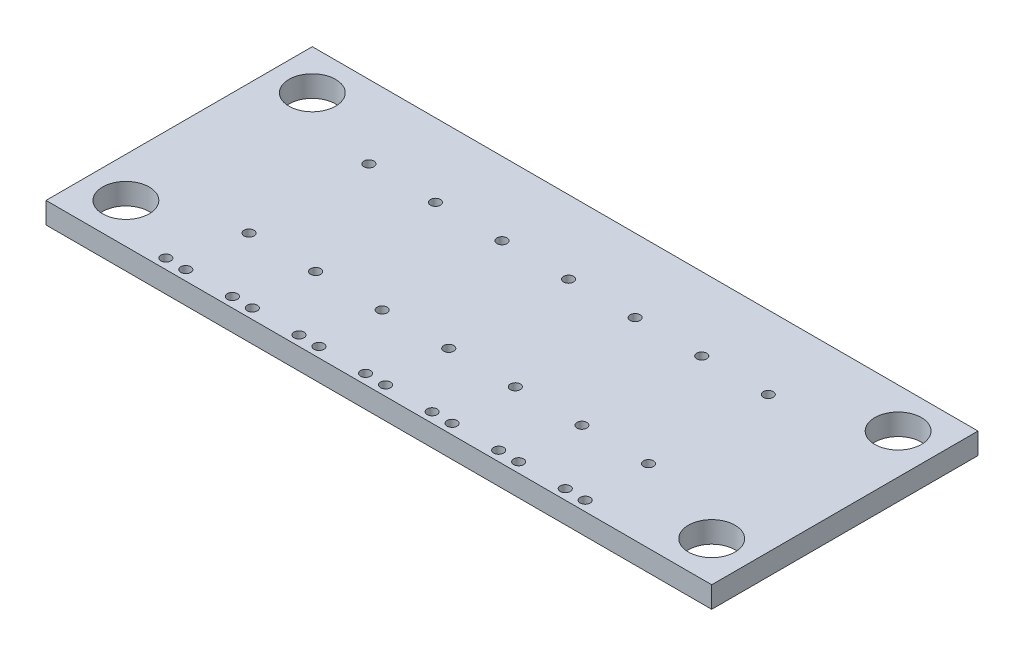
from build123d import *

# Parameters (mm, degrees)
SKETCH1_W           = 50
SKETCH1_H           = 20
SKETCH1_R           = 1.75
BOSS_EXTRUDE1_DEPTH = 1.6
SKETCH3_R           = 0.375
CUT_EXTRUDE1_DEPTH  = 2.6


with BuildPart() as part:
    # Sketch1 → Boss-Extrude1 (new body)
    with BuildSketch(Plane(origin=(0, 0, 0), x_dir=(1, 0, 0), z_dir=(0, 1, 0))):
        with Locations((25, 10)):
            Rectangle(SKETCH1_W, SKETCH1_H)
        with Locations((3, 17)):
            Circle(SKETCH1_R, mode=Mode.SUBTRACT)
        with Locations((47, 3)):
            Circle(SKETCH1_R, mode=Mode.SUBTRACT)
        with Locations((3, 3)):
            Circle(SKETCH1_R, mode=Mode.SUBTRACT)
        with Locations((47, 17)):
            Circle(SKETCH1_R, mode=Mode.SUBTRACT)
    extrude(amount=BOSS_EXTRUDE1_DEPTH)

    # Sketch3 → Cut-Extrude1 (cut, through all)
    with BuildSketch(Plane(origin=(0, 1.6, 0), x_dir=(1, 0, 0), z_dir=(0, 1, 0))):
        with Locations((8.25, 0.75)):
            Circle(SKETCH3_R)
        with Locations((9.75, 0.75)):
            Circle(SKETCH3_R)
        with Locations((9.75, 5.5)):
            Circle(SKETCH3_R)
        with Locations((9.75, 14.5)):
            Circle(SKETCH3_R)
        with Locations((13.25, 0.75)):
            Circle(SKETCH3_R)
        with Locations((14.75, 0.75)):
            Circle(SKETCH3_R)
        with Locations((14.75, 14.5)):
            Circle(SKETCH3_R)
        with Locations((14.75, 5.5)):
            Circle(SKETCH3_R)
        with Locations((18.25, 0.75)):
            Circle(SKETCH3_R)
        with Locations((19.75, 0.75)):
            Circle(SKETCH3_R)
        with Locations((19.75, 14.5)):
            Circle(SKETCH3_R)
        with Locations((19.75, 5.5)):
            Circle(SKETCH3_R)
        with Locations((23.25, 0.75)):
            Circle(SKETCH3_R)
        with Locations((24.75, 0.75)):
            Circle(SKETCH3_R)
        with Locations((24.75, 14.5)):
            Circle(SKETCH3_R)
        with Locations((24.75, 5.5)):
            Circle(SKETCH3_R)
        with Locations((28.25, 0.75)):
            Circle(SKETCH3_R)
        with Locations((29.75, 0.75)):
            Circle(SKETCH3_R)
        with Locations((29.75, 14.5)):
            Circle(SKETCH3_R)
        with Locations((29.75, 5.5)):
            Circle(SKETCH3_R)
        with Locations((33.25, 0.75)):
            Circle(SKETCH3_R)
        with Locations((34.75, 0.75)):
            Circle(SKETCH3_R)
        with Locations((34.75, 14.5)):
            Circle(SKETCH3_R)
        with Locations((34.75, 5.5)):
            Circle(SKETCH3_R)
        with Locations((38.25, 0.75)):
            Circle(SKETCH3_R)
        with Locations((39.75, 0.75)):
            Circle(SKETCH3_R)
        with Locations((39.75, 14.5)):
            Circle(SKETCH3_R)
        with Locations((39.75, 5.5)):
            Circle(SKETCH3_R)
    extrude(amount=-CUT_EXTRUDE1_DEPTH, mode=Mode.SUBTRACT)


solid = part.part
